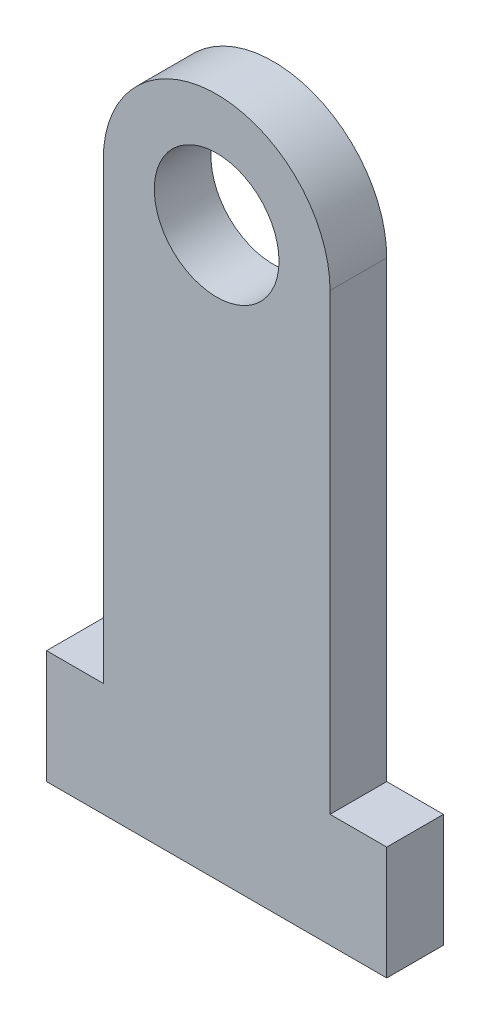
from build123d import *

# Parameters (mm, degrees)
BOSS_EXTRUDE1_DEPTH = 10
SKETCH2_R           = 11
CUT_EXTRUDE1_DEPTH  = 10


with BuildPart() as part:
    # Sketch1 → Boss-Extrude1 (new body)
    with BuildSketch(Plane.XY):
        Polygon((50, 20), (50, 100), (10, 100), (10, 20), (0, 20), (0, 0), (60, 0), (60, 20), align=None)
        with BuildLine():
            Line((50, 100), (10, 100))
            ThreePointArc((10, 100), (30, 120), (50, 100))
        make_face()
    extrude(amount=BOSS_EXTRUDE1_DEPTH)

    # Sketch2 → Cut-Extrude1 (cut)
    with BuildSketch(Plane.XY.offset(10)):
        with Locations((30, 100)):
            Circle(SKETCH2_R)
    extrude(amount=-CUT_EXTRUDE1_DEPTH, mode=Mode.SUBTRACT)


solid = part.part
